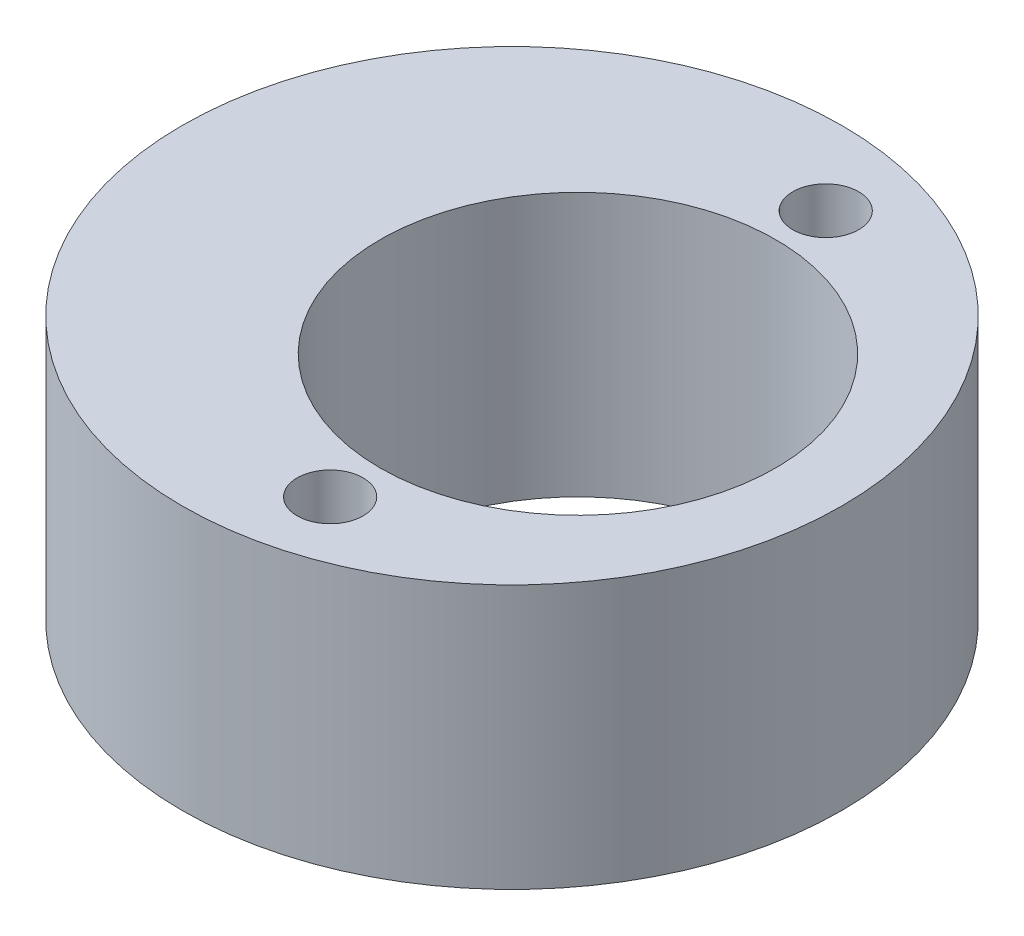
from build123d import *

# Parameters (mm, degrees)
SKETCH1_R           = 5
SKETCH1_R_2         = 3
BOSS_EXTRUDE1_DEPTH = 4
SKETCH2_R           = 0.5
CUT_EXTRUDE1_DEPTH  = 5


with BuildPart() as part:
    # Sketch1 → Boss-Extrude1 (new body)
    with BuildSketch(Plane(origin=(0, 0, 0), x_dir=(1, 0, 0), z_dir=(0, 1, 0))):
        with Locations((-1, 0)):
            Circle(SKETCH1_R)
        Circle(SKETCH1_R_2, mode=Mode.SUBTRACT)
    extrude(amount=BOSS_EXTRUDE1_DEPTH)

    # Sketch2 → Cut-Extrude1 (cut, through all)
    with BuildSketch(Plane(origin=(0, 4, 0), x_dir=(1, 0, 0), z_dir=(0, 1, 0))):
        with Locations((0, 3.757913747)):
            Circle(SKETCH2_R)
        with Locations((0, -3.757913747)):
            Circle(SKETCH2_R)
    extrude(amount=-CUT_EXTRUDE1_DEPTH, mode=Mode.SUBTRACT)


solid = part.part
